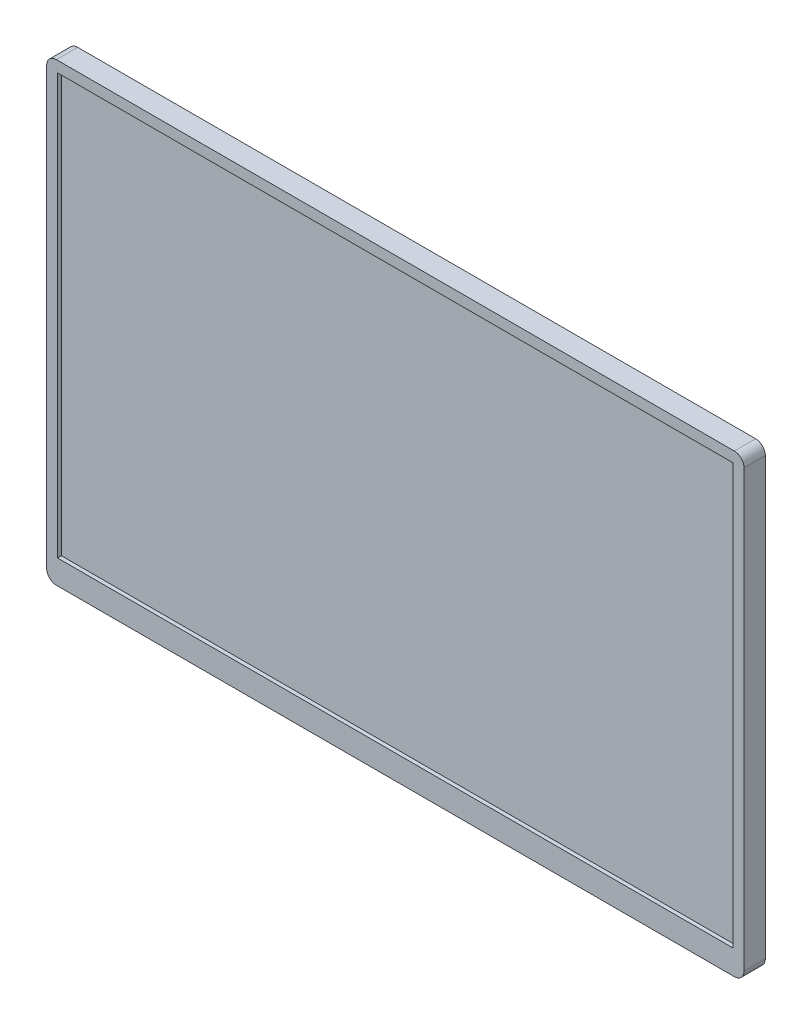
from build123d import *

# Parameters (mm, degrees)
SKETCH1_W           = 360
SKETCH1_H           = 235
BOSS_EXTRUDE1_DEPTH = 11
FILLET1_R           = 5
SKETCH2_W           = 348.8
SKETCH2_H           = 216.9
CUT_EXTRUDE1_DEPTH  = 2


with BuildPart() as part:
    # Sketch1 → Boss-Extrude1 (new body)
    with BuildSketch(Plane.XY):
        Rectangle(SKETCH1_W, SKETCH1_H)
    extrude(amount=BOSS_EXTRUDE1_DEPTH)

    # Fillet1
    fillet1_edges = [part.edges().sort_by_distance(p)[0] for p in [
        (180, -117.5, 5.5),
        (-180, -117.5, 5.5),
        (-180, 117.5, 5.5),
        (180, 117.5, 5.5),
    ]]
    fillet(fillet1_edges, radius=FILLET1_R)

    # Sketch2 → Cut-Extrude1 (cut)
    with BuildSketch(Plane.XY.offset(11)):
        with Locations((0, 3.45)):
            Rectangle(SKETCH2_W, SKETCH2_H)
    extrude(amount=-CUT_EXTRUDE1_DEPTH, mode=Mode.SUBTRACT)


solid = part.part
